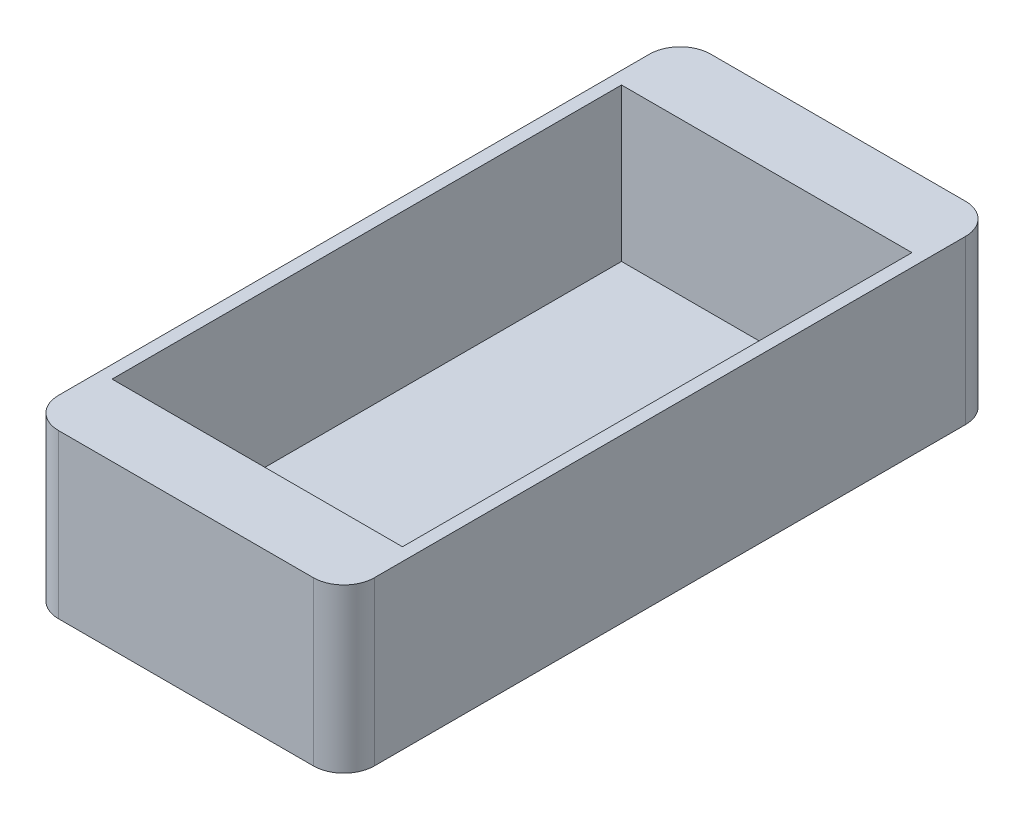
from build123d import *

# Parameters (mm, degrees)
SKETCH_1_W      = 31
SKETCH_1_H      = 64
SKETCH_1_W_2    = 28.5
SKETCH_1_H_2    = 50
EXTRUDE_1_DEPTH = 15
SKETCH_2_W      = 31
SKETCH_2_H      = 64
EXTRUDE_2_DEPTH = 1
FILLET_1_R      = 3


with BuildPart() as part:
    # 草图1 → 凸台-拉伸1 (new body)
    with BuildSketch(Plane(origin=(0, 0, 0), x_dir=(1, 0, 0), z_dir=(0, 1, 0))):
        Rectangle(SKETCH_1_W, SKETCH_1_H)
        Rectangle(SKETCH_1_W_2, SKETCH_1_H_2, mode=Mode.SUBTRACT)
    extrude(amount=EXTRUDE_1_DEPTH)

    # 草图2 → 凸台-拉伸2 (add)
    with BuildSketch(Plane(origin=(0, 0, 0), x_dir=(1, 0, 0), z_dir=(0, 1, 0))):
        Rectangle(SKETCH_2_W, SKETCH_2_H)
    extrude(amount=-EXTRUDE_2_DEPTH)

    # 圆角1
    fillet_1_edges = [part.edges().sort_by_distance(p)[0] for p in [
        (15.5, 7, 32),
        (-15.5, 7, 32),
        (-15.5, 7, -32),
        (15.5, 7, -32),
    ]]
    fillet(fillet_1_edges, radius=FILLET_1_R)


solid = part.part
